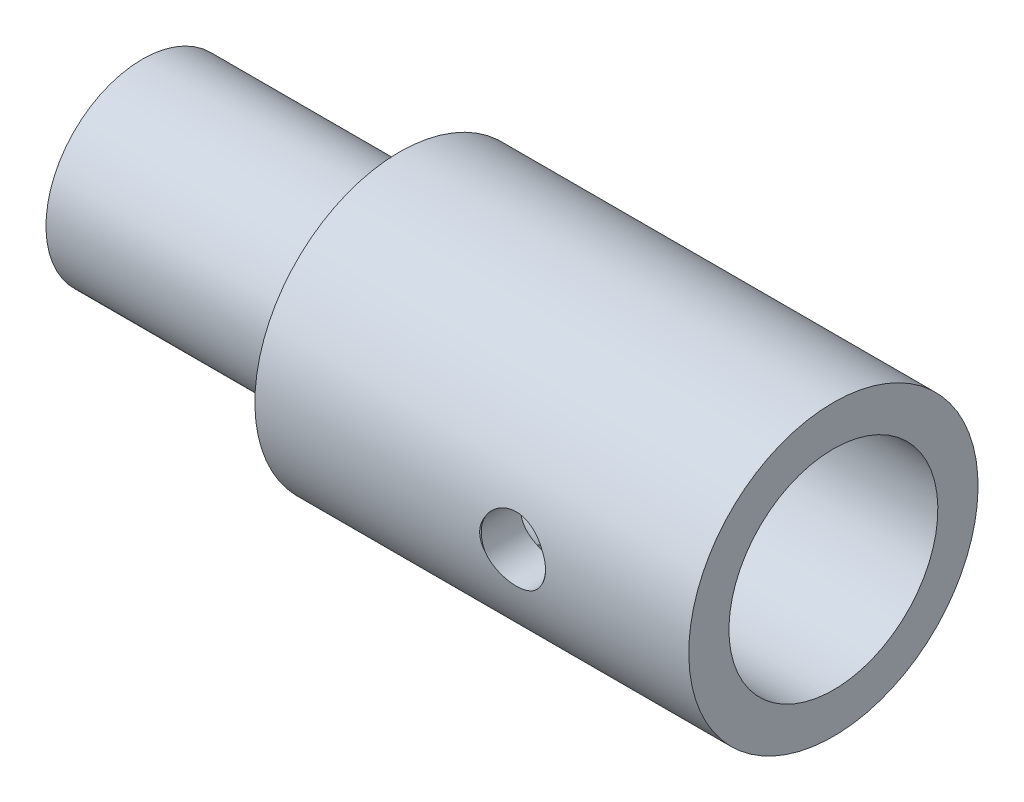
from build123d import *

# Parameters (mm, degrees)
F_2_0_2_DIAMETER_HOLE1_D           = 2
F_2_0_2_DIAMETER_HOLE1_CSINK_D     = 2.05
F_2_0_2_DIAMETER_HOLE1_CSINK_ANGLE = 90


with BuildPart() as part:
    # Sketch1 → Revolve1 (revolve)
    with BuildSketch(Plane.XY):
        Polygon((9.549685022, 1.278125845), (9.549685022, 2.528125845), (-2.450314978, 2.528125845), (-3.950314978, 2.528125845), (-3.950314978, 1.028125845), (-11.950314978, 1.028125845), (-11.950314978, -0.471874155), (-2.450314978, -0.471874155), (-2.450314978, 1.028125845), (1.549685022, 1.028125845), (1.549685022, 1.278125845), align=None)
    revolve(axis=Axis((0, -1.971874155, 0), (-1, 0, 0)))

    # Ø2.0 (2) Diameter Hole1 (through all)
    with Locations(Plane(origin=(4.068165659, -1.965730097, 4.499995806), x_dir=(0, 0.999999068, -0.001365346), z_dir=(0, 0.001365346, 0.999999068))):
        with Locations((0, 0)):
            CounterSinkHole(F_2_0_2_DIAMETER_HOLE1_D / 2, F_2_0_2_DIAMETER_HOLE1_CSINK_D / 2, counter_sink_angle=F_2_0_2_DIAMETER_HOLE1_CSINK_ANGLE)


solid = part.part
